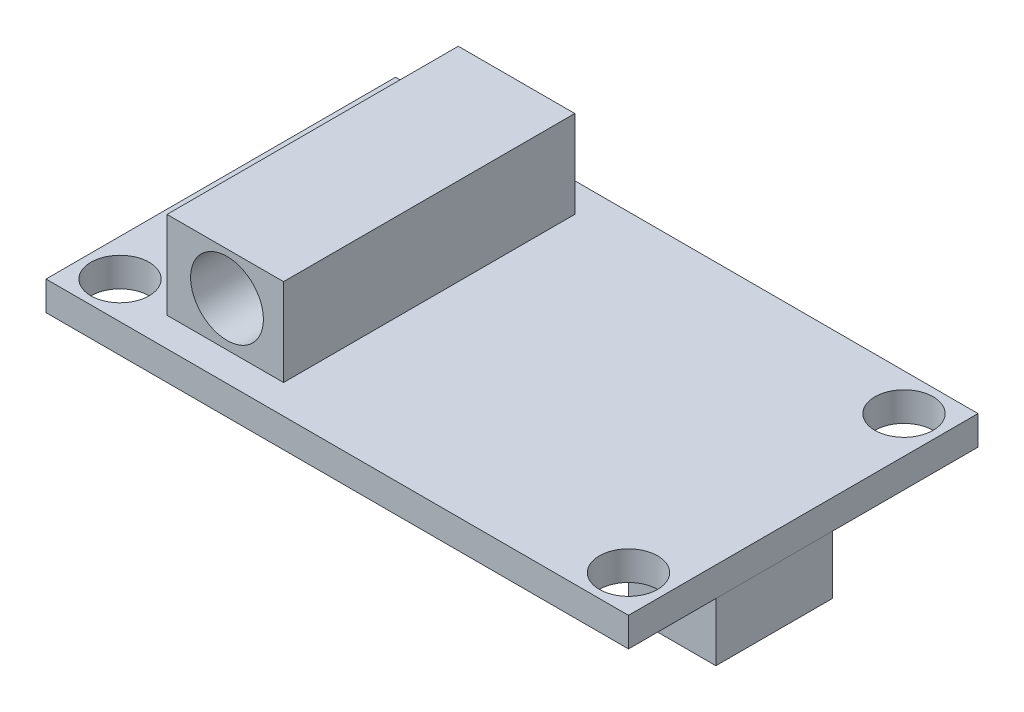
from build123d import *

# Parameters (mm, degrees)
SKETCH2_W             = 31.75
SKETCH2_H             = 19.05
SKETCH2_R             = 1.5875
BOSS_EXTRUDE1_DEPTH   = 1.5875
SKETCH2_5_W           = 4.7625
SKETCH2_5_H           = 6.35
BOSS_EXTRUDE2_DEPTH   = 3.175
BOSS_EXTRUDE2_2_DEPTH = 3.175
BOSS_EXTRUDE3_START   = 1.5875
SKETCH2_6_W           = 6.35
SKETCH2_6_H           = 15.875
BOSS_EXTRUDE3_DEPTH   = 4.7625
SKETCH3_R             = 1.984375
CUT_EXTRUDE1_DEPTH    = 12.7625


with BuildPart() as part:
    # Sketch2 → Boss-Extrude1 (new body)
    with BuildSketch(Plane(origin=(0, 0, 0), x_dir=(1, 0, 0), z_dir=(0, 1, 0))):
        Rectangle(SKETCH2_W, SKETCH2_H)
        with Locations((-13.858094262, 7.508094262)):
            Circle(SKETCH2_R, mode=Mode.SUBTRACT)
        with Locations((-13.858094262, -7.508094262)):
            Circle(SKETCH2_R, mode=Mode.SUBTRACT)
        with Locations((13.858094262, -7.508094262)):
            Circle(SKETCH2_R, mode=Mode.SUBTRACT)
        with Locations((13.858094262, 7.508094262)):
            Circle(SKETCH2_R, mode=Mode.SUBTRACT)
    extrude(amount=BOSS_EXTRUDE1_DEPTH)

    # Sketch2_6 → Boss-Extrude3 (add)
    with BuildSketch(Plane(origin=(0, 0, 0), x_dir=(1, 0, 0), z_dir=(0, 1, 0)).offset(BOSS_EXTRUDE3_START)):
        with Locations((-7.690266393, 0)):
            Rectangle(SKETCH2_6_W, SKETCH2_6_H)
    extrude(amount=BOSS_EXTRUDE3_DEPTH)

    # Sketch3 → Cut-Extrude1 (cut)
    with BuildSketch(Plane.XY.offset(7.9375)):
        with Locations((-7.596610365, 4.018415317)):
            Circle(SKETCH3_R)
    extrude(amount=-CUT_EXTRUDE1_DEPTH, mode=Mode.SUBTRACT)


with BuildPart() as body_2:
    # Sketch2_5 → Boss-Extrude2 (new body)
    with BuildSketch(Plane(origin=(0, 0, 0), x_dir=(1, 0, 0), z_dir=(0, 1, 0))):
        with Locations((-13.49375, 2.38125)):
            Rectangle(SKETCH2_5_W, SKETCH2_5_H)
    extrude(amount=-BOSS_EXTRUDE2_DEPTH)


with BuildPart() as body_3:
    # Sketch2_5 → Boss-Extrude2 2 (new body)
    with BuildSketch(Plane(origin=(0, 0, 0), x_dir=(1, 0, 0), z_dir=(0, 1, 0))):
        with Locations((13.49375, -1.5875)):
            Rectangle(SKETCH2_5_W, SKETCH2_5_H)
    extrude(amount=-BOSS_EXTRUDE2_2_DEPTH)


solid = Compound([part.part, body_2.part, body_3.part])
